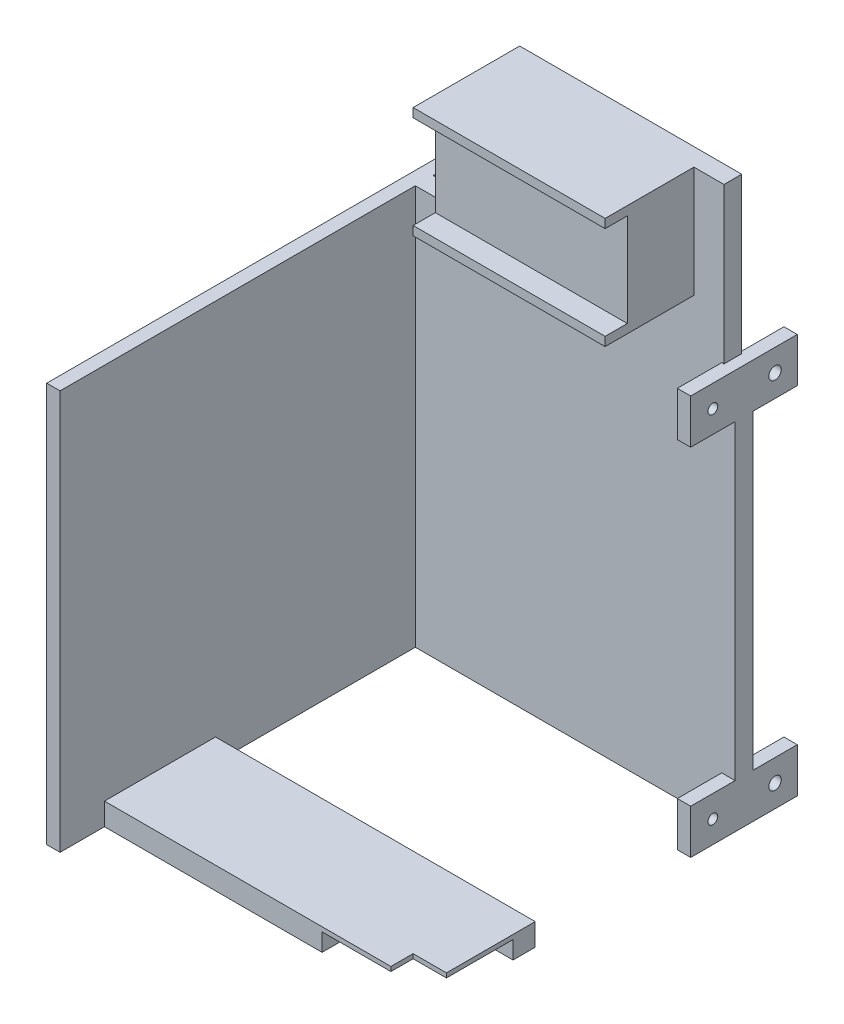
from build123d import *

# Parameters (mm, degrees)
EXTRUDE_1_DEPTH     = 4
SKETCH_3_W          = 43.235473071
SKETCH_3_H          = 2
EXTRUDE_2_DEPTH     = 20
SKETCH_4_W          = 43.235473071
SKETCH_4_H          = 21
EXTRUDE_3_DEPTH     = 15
SKETCH_8_W          = 3
SKETCH_8_H          = 10
EXTRUDE_4_DEPTH     = 10
SKETCH_10_R         = 1.4
CUT_EXTRUDE_1_DEPTH = 83
SKETCH_11_W         = 3
SKETCH_11_H         = 90
EXTRUDE_5_DEPTH     = 80
SKETCH_12_W         = 75
SKETCH_12_H         = 25
EXTRUDE_6_DEPTH     = 5
SKETCH_13_W         = 23
SKETCH_13_H         = 20
CUT_EXTRUDE_2_DEPTH = 4
CUT_EXTRUDE_3_REACH = 123
SKETCH_14_W         = 7.5
SKETCH_14_H         = 5
SKETCH_15_R         = 1.1
CUT_EXTRUDE_4_DEPTH = 10
SKETCH_17_W         = 3
SKETCH_17_H         = 10
EXTRUDE_7_DEPTH     = 10
SKETCH_18_R         = 1.1
CUT_EXTRUDE_5_DEPTH = 3
SKETCH_19_W         = 3
SKETCH_19_H         = 10
EXTRUDE_8_DEPTH     = 10
SKETCH_20_R         = 1.1
CUT_EXTRUDE_6_DEPTH = 3


with BuildPart() as part:
    # 草圖1 → 填料-伸長1 (new body)
    with BuildSketch(Plane.XY):
        Polygon((-37.5, 45), (-35, 45), (-35, 80), (15, 80), (15, 45), (37.5, 45), (37.5, -45), (-37.5, -45), align=None)
    extrude(amount=EXTRUDE_1_DEPTH)

    # 草圖3 → 填料-伸長2 (add)
    with BuildSketch(Plane.XY.offset(4)):
        with Locations((-6.617736535, 56)):
            Rectangle(SKETCH_3_W, SKETCH_3_H)
        with Locations((-6.617736535, 79)):
            Rectangle(SKETCH_3_W, SKETCH_3_H)
    extrude(amount=EXTRUDE_2_DEPTH)

    # 草圖4 → 填料-伸長3 (add)
    with BuildSketch(Plane.XY.offset(4)):
        with Locations((-6.617736535, 67.5)):
            Rectangle(SKETCH_4_W, SKETCH_4_H)
    extrude(amount=EXTRUDE_3_DEPTH)

    # 草圖8 → 填料-伸長4 (add)
    with BuildSketch(Plane(origin=(0, 0, 0), x_dir=(-1, 0, 0), z_dir=(0, 0, -1))):
        with Locations((-36, 40)):
            Rectangle(SKETCH_8_W, SKETCH_8_H)
        with Locations((36, 40)):
            Rectangle(SKETCH_8_W, SKETCH_8_H)
        with Locations((36, -40)):
            Rectangle(SKETCH_8_W, SKETCH_8_H)
        with Locations((-36, -40)):
            Rectangle(SKETCH_8_W, SKETCH_8_H)
    extrude(amount=EXTRUDE_4_DEPTH)

    # 草圖10 → 除料-伸長1 (cut)
    with BuildSketch(Plane(origin=(37.5, 0, 0), x_dir=(0, 0, -1), z_dir=(1, 0, 0))):
        with Locations((5, 40)):
            Circle(SKETCH_10_R)
        with Locations((5, -40)):
            Circle(SKETCH_10_R)
    extrude(amount=-CUT_EXTRUDE_1_DEPTH, mode=Mode.SUBTRACT)

    # 草圖11 → 填料-伸長5 (add)
    with BuildSketch(Plane.XY.offset(4)):
        with Locations((36, 0)):
            Rectangle(SKETCH_11_W, SKETCH_11_H)
    extrude(amount=EXTRUDE_5_DEPTH)

    # 草圖12 → 填料-伸長6 (add)
    with BuildSketch(Plane.XZ.offset(45)):
        with Locations((0, 61.5)):
            Rectangle(SKETCH_12_W, SKETCH_12_H)
    extrude(amount=-EXTRUDE_6_DEPTH)

    # 草圖13 → 除料-伸長2 (cut)
    with BuildSketch(Plane.XZ.offset(45)):
        with Locations((-26, 64)):
            Rectangle(SKETCH_13_W, SKETCH_13_H)
    extrude(amount=-CUT_EXTRUDE_2_DEPTH, mode=Mode.SUBTRACT)

    # 草圖14 → 除料-伸長3 (cut, up to next)
    with BuildSketch(Plane.XZ.offset(41), mode=Mode.PRIVATE) as cut_extrude_3_sk1:
        with Locations((-33.75, 71.5)):
            Rectangle(SKETCH_14_W, SKETCH_14_H)
    cut_extrude_3_tool1 = extrude(cut_extrude_3_sk1.sketch, amount=-CUT_EXTRUDE_3_REACH, mode=Mode.PRIVATE) & part.part
    add(cut_extrude_3_tool1.solids().sort_by_distance((-33.75, -41, 71.5))[0], mode=Mode.SUBTRACT)

    # 草圖15 → 除料-伸長4 (cut)
    with BuildSketch(Plane(origin=(15, 0, 0), x_dir=(0, 0, -1), z_dir=(1, 0, 0))):
        with Locations((-16.1, 72.2)):
            Circle(SKETCH_15_R)
        with Locations((-16.1, 62.8)):
            Circle(SKETCH_15_R)
    extrude(amount=-CUT_EXTRUDE_4_DEPTH, mode=Mode.SUBTRACT)

    # 草圖17 → 填料-伸長7 (add)
    with BuildSketch(Plane.XY.offset(4)):
        with Locations((-36, 40)):
            Rectangle(SKETCH_17_W, SKETCH_17_H)
    extrude(amount=EXTRUDE_7_DEPTH)

    # 草圖18 → 除料-伸長5 (cut)
    with BuildSketch(Plane.ZY.offset(37.5)):
        with Locations((9, 40)):
            Circle(SKETCH_18_R)
    extrude(amount=-CUT_EXTRUDE_5_DEPTH, mode=Mode.SUBTRACT)

    # 草圖19 → 填料-伸長8 (add)
    with BuildSketch(Plane.XY.offset(4)):
        with Locations((-36, -40)):
            Rectangle(SKETCH_19_W, SKETCH_19_H)
    extrude(amount=EXTRUDE_8_DEPTH)

    # 草圖20 → 除料-伸長6 (cut)
    with BuildSketch(Plane.ZY.offset(37.5)):
        with Locations((9, -40)):
            Circle(SKETCH_20_R)
    extrude(amount=-CUT_EXTRUDE_6_DEPTH, mode=Mode.SUBTRACT)


with BuildPart() as body_2:
    # 鏡射1: mirrored copy
    add(part.part.mirror(Plane(origin=(37.5, 0, 4), x_dir=(0, 0, 1), z_dir=(1, 0, 0))))


solid = body_2.part
